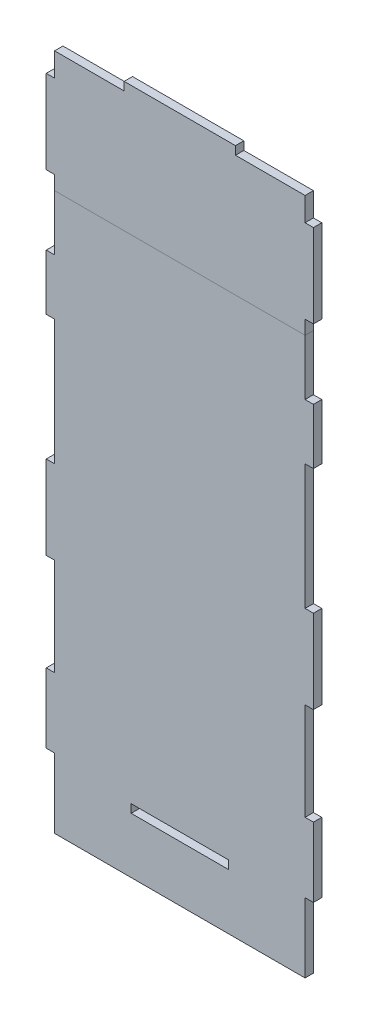
from build123d import *

# Parameters (mm, degrees)
SKETCH1_W           = 90
SKETCH1_H           = 200
BOSS_EXTRUDE1_DEPTH = 3
SKETCH3_W           = 3
SKETCH3_H           = 20
SKETCH3_H_2         = 30
SKETCH3_H_3         = 25
BOSS_EXTRUDE2_DEPTH = 3
SKETCH4_W           = 90
SKETCH4_H           = 43.5
SKETCH4_W_2         = 40
SKETCH4_H_2         = 3
BOSS_EXTRUDE4_DEPTH = 3
SKETCH7_W           = 35
SKETCH7_H           = 3
CUT_EXTRUDE3_DEPTH  = 4
SKETCH12_W          = 3
SKETCH12_H          = 30
BOSS_EXTRUDE7_DEPTH = 3


with BuildPart() as part:
    # Sketch1 → Boss-Extrude1 (new body)
    with BuildSketch(Plane.XY):
        with Locations((45, 100)):
            Rectangle(SKETCH1_W, SKETCH1_H)
    extrude(amount=BOSS_EXTRUDE1_DEPTH)

    # Sketch3 → Boss-Extrude2 (add)
    with BuildSketch(Plane.XY.offset(3)):
        with Locations((-1.5, 170)):
            Rectangle(SKETCH3_W, SKETCH3_H)
        with Locations((91.5, 170)):
            Rectangle(SKETCH3_W, SKETCH3_H)
        with Locations((91.5, 100)):
            Rectangle(SKETCH3_W, SKETCH3_H_2)
        with Locations((-1.5, 100)):
            Rectangle(SKETCH3_W, SKETCH3_H_2)
        with Locations((-1.5, 37.5)):
            Rectangle(SKETCH3_W, SKETCH3_H_3)
        with Locations((91.5, 37.5)):
            Rectangle(SKETCH3_W, SKETCH3_H_3)
    extrude(amount=-BOSS_EXTRUDE2_DEPTH)

    # Sketch7 → Cut-Extrude3 (cut)
    with BuildSketch(Plane(origin=(0, 0, 0), x_dir=(-1, 0, 0), z_dir=(0, 0, -1))):
        with Locations((-45, 21.5)):
            Rectangle(SKETCH7_W, SKETCH7_H)
    extrude(amount=-CUT_EXTRUDE3_DEPTH, mode=Mode.SUBTRACT)


with BuildPart() as body_2:
    # Sketch4 → Boss-Extrude4 (new body)
    with BuildSketch(Plane.XY.offset(3)):
        with Locations((45, 221.75)):
            Rectangle(SKETCH4_W, SKETCH4_H)
        with Locations((45, 245)):
            Rectangle(SKETCH4_W_2, SKETCH4_H_2)
    extrude(amount=-BOSS_EXTRUDE4_DEPTH)

    # Sketch12 → Boss-Extrude7 (add)
    with BuildSketch(Plane.XY.offset(3)):
        with Locations((-1.5, 220)):
            Rectangle(SKETCH12_W, SKETCH12_H)
        with Locations((91.5, 220)):
            Rectangle(SKETCH12_W, SKETCH12_H)
    extrude(amount=-BOSS_EXTRUDE7_DEPTH)


solid = Compound([part.part, body_2.part])
